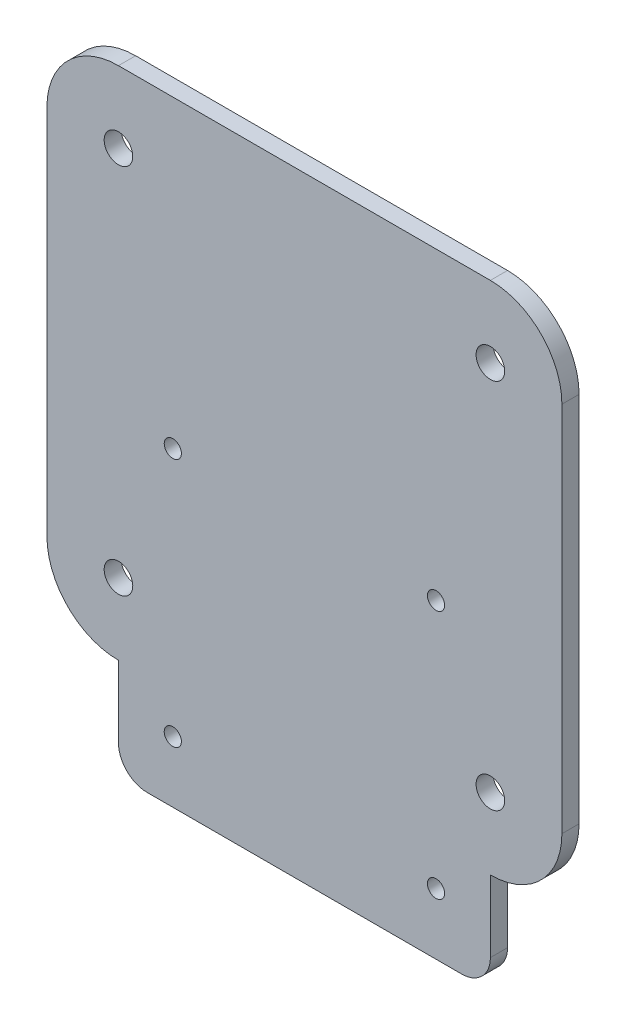
from build123d import *

# Parameters (mm, degrees)
SKETCH1_R           = 1.5
SKETCH1_R_2         = 2.5
BOSS_EXTRUDE1_DEPTH = 3


with BuildPart() as part:
    # Sketch1 → Boss-Extrude1 (new body)
    with BuildSketch(Plane.XY):
        with BuildLine():
            Line((-32.5, 45), (32.5, 45))
            ThreePointArc((32.5, 45), (41.338834765, 41.338834765), (45, 32.5))
            Line((45, 32.5), (45, -32.5))
            ThreePointArc((45, -32.5), (41.338834765, -41.338834765), (32.5, -45))
            Line((32.5, -45), (32.5, -57.5))
            ThreePointArc((32.5, -57.5), (31.035533906, -61.035533906), (27.5, -62.5))
            Line((27.5, -62.5), (-27.5, -62.5))
            ThreePointArc((-27.5, -62.5), (-31.035533906, -61.035533906), (-32.5, -57.5))
            Line((-32.5, -57.5), (-32.5, -45))
            ThreePointArc((-32.5, -45), (-41.338834765, -41.338834765), (-45, -32.5))
            Line((-45, -32.5), (-45, 32.5))
            ThreePointArc((-45, 32.5), (-41.338834765, 41.338834765), (-32.5, 45))
        make_face()
        with Locations((-23, -8.2)):
            Circle(SKETCH1_R, mode=Mode.SUBTRACT)
        with Locations((23, -8.2)):
            Circle(SKETCH1_R, mode=Mode.SUBTRACT)
        with Locations((23, -51.8)):
            Circle(SKETCH1_R, mode=Mode.SUBTRACT)
        with Locations((-23, -51.8)):
            Circle(SKETCH1_R, mode=Mode.SUBTRACT)
        with Locations((-32.5, 32.5)):
            Circle(SKETCH1_R_2, mode=Mode.SUBTRACT)
        with Locations((32.5, 32.5)):
            Circle(SKETCH1_R_2, mode=Mode.SUBTRACT)
        with Locations((32.5, -32.5)):
            Circle(SKETCH1_R_2, mode=Mode.SUBTRACT)
        with Locations((-32.5, -32.5)):
            Circle(SKETCH1_R_2, mode=Mode.SUBTRACT)
    extrude(amount=BOSS_EXTRUDE1_DEPTH)


solid = part.part
